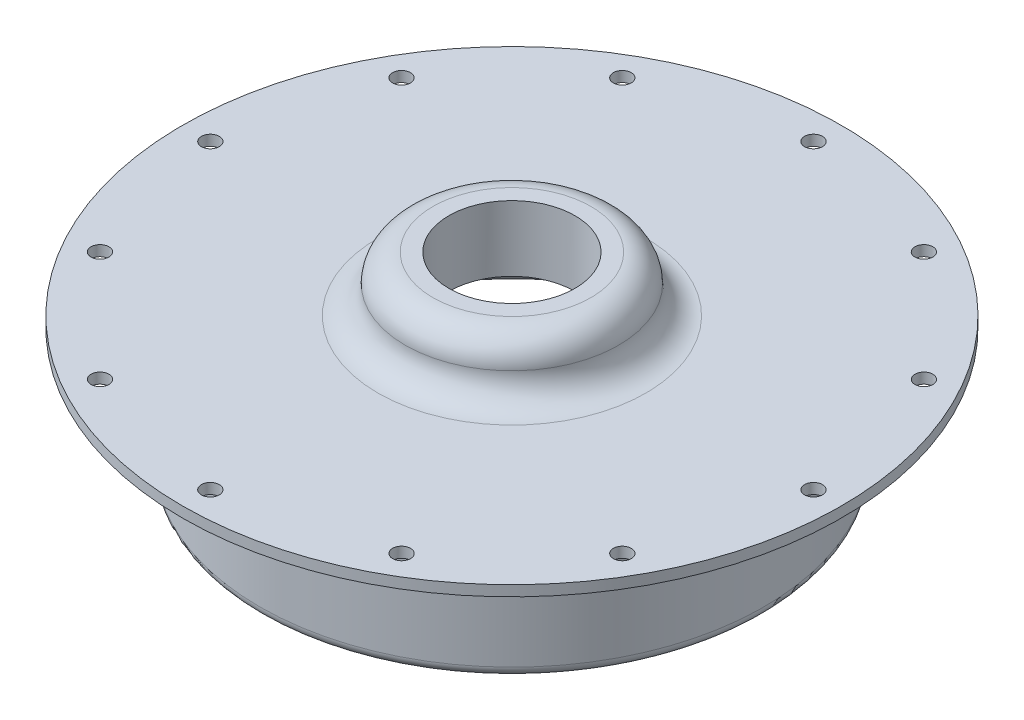
from build123d import *

# Parameters (mm, degrees)
F_36_0_1065_DIAMETER_HOLE1_D = 2.7051
CIRPATTERN1_COUNT            = 12
F_3_4_0_75_DIAMETER_HOLE1_D  = 19.05


with BuildPart() as part:
    # Sketch1 → Revolve1 (revolve)
    with BuildSketch(Plane.XY):
        with BuildLine():
            Line((-49.784, 0), (-39.6875, 0))
            ThreePointArc((-39.6875, 0), (-38.564967985, -0.464967985), (-38.1, -1.5875))
            Line((-38.1, -1.5875), (-38.1, -17.4625))
            ThreePointArc((-38.1, -17.4625), (-36.5125, -19.05), (-34.925, -17.4625))
            Line((-34.925, -17.4625), (-34.925, -3.175))
            ThreePointArc((-34.925, -3.175), (-33.99506403, -0.92993597), (-31.75, 0))
            Line((-31.75, 0), (-5.588, 0))
            Line((-5.588, 0), (-5.588, 9.906))
            Line((-5.588, 9.906), (-11.938, 9.906))
            ThreePointArc((-11.938, 9.906), (-14.87903388, 8.68778388), (-16.09725, 5.74675))
            ThreePointArc((-16.09725, 5.74675), (-17.31546612, 2.80571612), (-20.2565, 1.5875))
            Line((-20.2565, 1.5875), (-49.784, 1.5875))
            Line((-49.784, 1.5875), (-49.784, 0))
        make_face()
    revolve(axis=Axis((0, 55, 0), (0, -1, 0)))

    # #36 (0.1065) Diameter Hole1 (through all)
    with Locations(Plane(origin=(0, 1.5875, 0), x_dir=(1, 0, 0), z_dir=(0, 1, 0))):
        with Locations((-45.5549, 0)):
            f_36_0_1065_diameter_hole1 = Hole(F_36_0_1065_DIAMETER_HOLE1_D / 2)

    # CirPattern1: #36 (0.1065) Diameter Hole1 ×12 about axis
    cirpattern1_axis = Axis((0, 0, 0), (0, 1, 0))
    for i in range(1, CIRPATTERN1_COUNT):
        add(f_36_0_1065_diameter_hole1.rotate(cirpattern1_axis, i * 360 / CIRPATTERN1_COUNT), mode=Mode.SUBTRACT)

    # 3/4 (0.75) Diameter Hole1 (through all)
    with Locations(Plane(origin=(0, 9.906, 0), x_dir=(1, 0, 0), z_dir=(0, 1, 0))):
        with Locations((0, 0)):
            Hole(F_3_4_0_75_DIAMETER_HOLE1_D / 2)


solid = part.part
